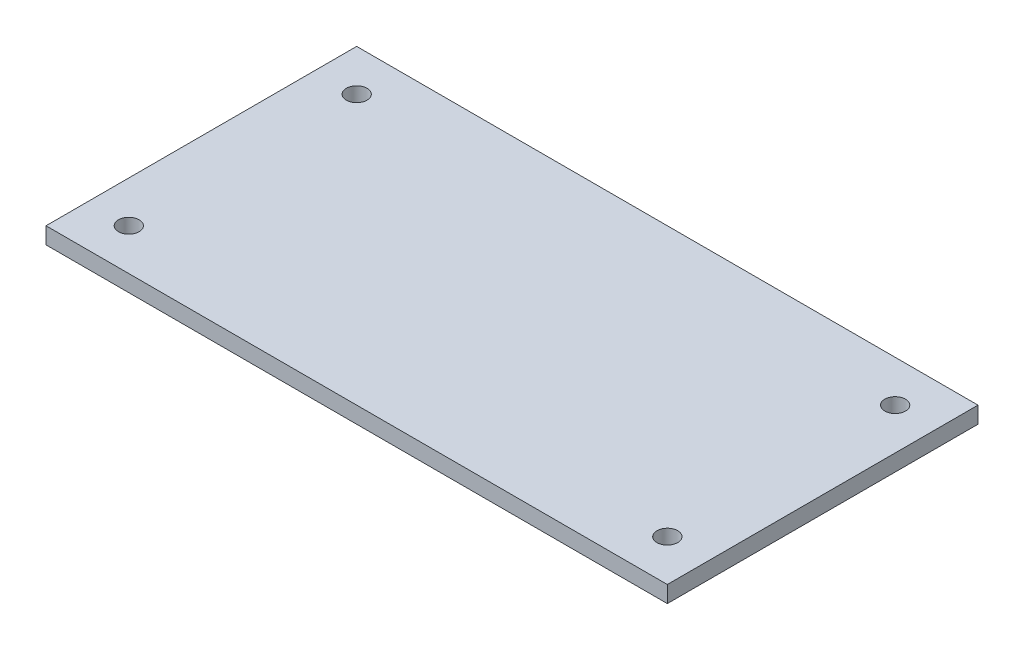
from build123d import *

# Parameters (mm, degrees)
SKETCH1_W           = 150
SKETCH1_H           = 75
SKETCH1_R           = 2.5
BOSS_EXTRUDE1_DEPTH = 4


with BuildPart() as part:
    # Sketch1 → Boss-Extrude1 (new body)
    with BuildSketch(Plane(origin=(0, 0, 0), x_dir=(1, 0, 0), z_dir=(0, 1, 0))):
        Rectangle(SKETCH1_W, SKETCH1_H)
        with Locations((-65, -27.5)):
            Circle(SKETCH1_R, mode=Mode.SUBTRACT)
        with Locations((-65, 27.5)):
            Circle(SKETCH1_R, mode=Mode.SUBTRACT)
        with Locations((65, -27.5)):
            Circle(SKETCH1_R, mode=Mode.SUBTRACT)
        with Locations((65, 27.5)):
            Circle(SKETCH1_R, mode=Mode.SUBTRACT)
    extrude(amount=BOSS_EXTRUDE1_DEPTH)


solid = part.part
